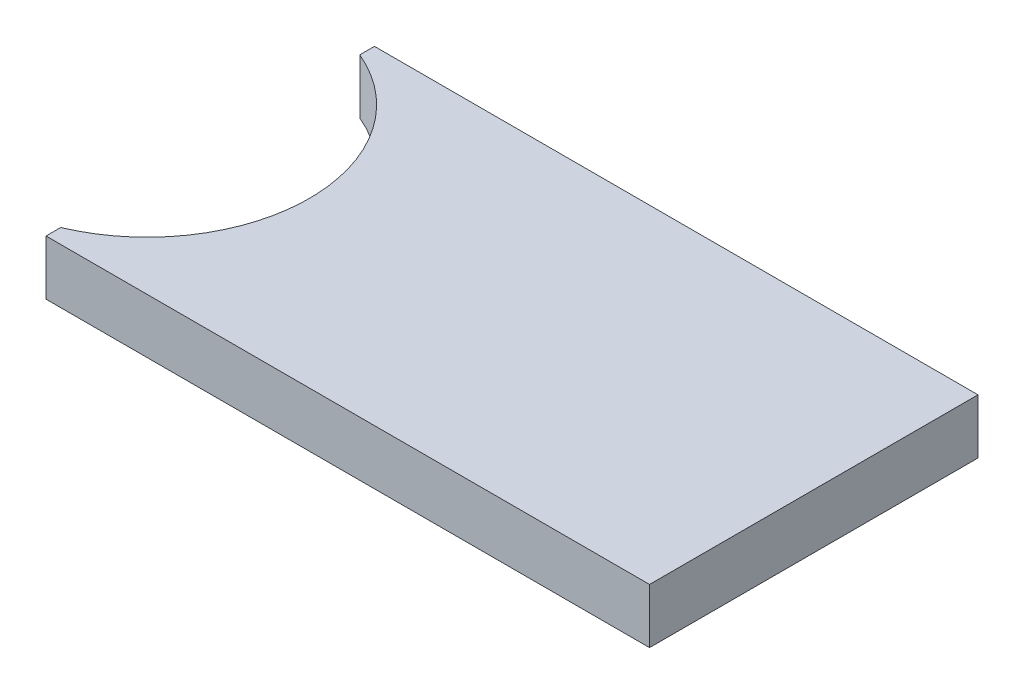
from build123d import *

# Parameters (mm, degrees)
EXTRUDE_1_DEPTH = 20


with BuildPart() as part:
    # Эскиз2 → Бобышка-Вытянуть1 (new body)
    with BuildSketch(Plane(origin=(0, 0, 0), x_dir=(1, 0, 0), z_dir=(0, 1, 0))):
        with BuildLine():
            Line((-110.249622757, 60), (-110.249622757, 54.636753066))
            ThreePointArc((-110.249622757, 54.636753066), (-74.022791587, 0), (-110.249622757, -54.636753066))
            Line((-110.249622757, -54.636753066), (-110.249622757, -60))
            Line((-110.249622757, -60), (110.249622757, -60))
            Line((110.249622757, -60), (110.249622757, 60))
            Line((110.249622757, 60), (-110.249622757, 60))
        make_face()
    extrude(amount=EXTRUDE_1_DEPTH)


solid = part.part
